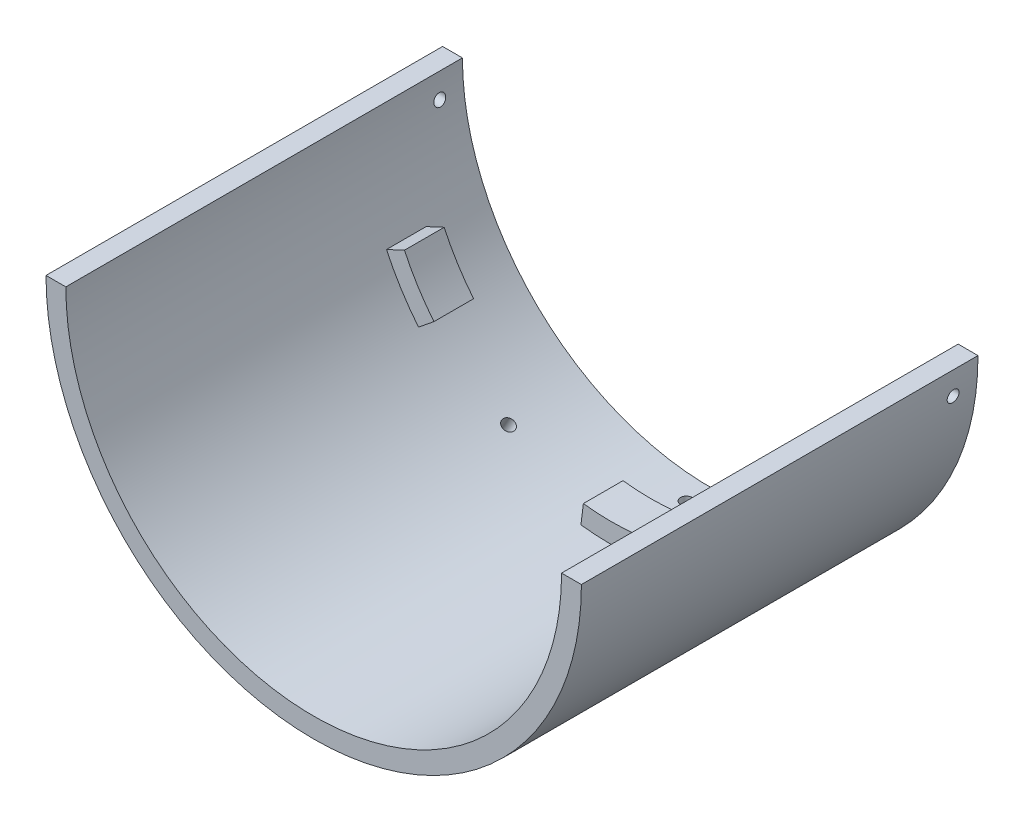
from build123d import *

# Parameters (mm, degrees)
BOSS_EXTRUDE1_DEPTH     = 100
BOSS_EXTRUDE3_DEPTH     = 10
CUT_EXTRUDE1_DEPTH      = 149
CUT_EXTRUDE1_DEPTH_BACK = 16
SKETCH4_R               = 1.5
CUT_EXTRUDE2_DEPTH      = 16
CUT_EXTRUDE2_DEPTH_BACK = 16
SKETCH5_R               = 1.5
CUT_EXTRUDE3_DEPTH      = 16
CUT_EXTRUDE3_DEPTH_BACK = 16
SKETCH6_R               = 1.5
CUT_EXTRUDE4_DEPTH      = 16
CUT_EXTRUDE4_DEPTH_BACK = 16
SKETCH7_R               = 1.5


with BuildPart() as part:
    # Sketch1 → Boss-Extrude1 (new body)
    with BuildSketch(Plane.XY):
        with BuildLine():
            ThreePointArc((62.5, 0), (0, -62.5), (-62.5, 0))
            Line((-62.5, 0), (-67.5, 0))
            ThreePointArc((-67.5, 0), (0, -67.5), (67.5, 0))
            Line((67.5, 0), (62.5, 0))
        make_face()
    extrude(amount=BOSS_EXTRUDE1_DEPTH)

    # Sketch3 → Boss-Extrude3 (add)
    with BuildSketch(Plane.XY.offset(15)):
        with BuildLine():
            Line((-52.112697755, -24.30055005), (-56.64423669, -26.413641359))
            ThreePointArc((-56.64423669, -26.413641359), (-53.00300601, -33.119954015), (-48.571622591, -39.332524441))
            Line((-48.571622591, -39.332524441), (-44.685892784, -36.185922485))
            ThreePointArc((-44.685892784, -36.185922485), (-48.762765529, -30.470357693), (-52.112697755, -24.30055005))
        make_face()
        with BuildLine():
            ThreePointArc((48.571622591, -39.332524441), (53.00300601, -33.119954015), (56.64423669, -26.413641359))
            Line((56.64423669, -26.413641359), (52.112697755, -24.30055005))
            ThreePointArc((52.112697755, -24.30055005), (48.762765529, -30.470357693), (44.685892784, -36.185922485))
            Line((44.685892784, -36.185922485), (48.571622591, -39.332524441))
        make_face()
        with BuildLine():
            Line((-7.007487246, -57.071403719), (-7.616833963, -62.034134478))
            ThreePointArc((-7.616833963, -62.034134478), (0, -62.5), (7.616833963, -62.034134478))
            Line((7.616833963, -62.034134478), (7.007487246, -57.071403719))
            ThreePointArc((7.007487246, -57.071403719), (0, -57.5), (-7.007487246, -57.071403719))
        make_face()
    extrude(amount=BOSS_EXTRUDE3_DEPTH)

    # Sketch4 → Cut-Extrude1 (cut, two sides: drawn at the far end of the back side and taken through both)
    with BuildSketch(Plane.ZY.offset(-62.5).offset(-CUT_EXTRUDE1_DEPTH_BACK)):
        with Locations((6, -6)):
            Circle(SKETCH4_R)
    extrude(amount=CUT_EXTRUDE1_DEPTH + CUT_EXTRUDE1_DEPTH_BACK, mode=Mode.SUBTRACT)

    # Sketch5 → Cut-Extrude2 (cut, two sides: drawn at the far end of the back side and taken through both)
    with BuildSketch(Plane(origin=(0, -62.5, 0), x_dir=(1, 0, 0), z_dir=(0, 1, 0)).offset(-CUT_EXTRUDE2_DEPTH_BACK)):
        with Locations((0, -6)):
            Circle(SKETCH5_R)
    extrude(amount=CUT_EXTRUDE2_DEPTH + CUT_EXTRUDE2_DEPTH_BACK, mode=Mode.SUBTRACT)

    # Sketch6 → Cut-Extrude3 (cut, two sides: drawn at the far end of the back side and taken through both)
    with BuildSketch(Plane(origin=(-30.300601265, -54.663731696, 0), x_dir=(0.8746197071393957, -0.48480962024633734, 0), z_dir=(0.48480962024633734, 0.8746197071393957, 0)).offset(-CUT_EXTRUDE3_DEPTH_BACK)):
        with Locations((-0.663731696, -20)):
            Circle(SKETCH6_R)
    extrude(amount=CUT_EXTRUDE3_DEPTH + CUT_EXTRUDE3_DEPTH_BACK, mode=Mode.SUBTRACT)

    # Sketch7 → Cut-Extrude4 (cut, two sides: drawn at the far end of the back side and taken through both)
    with BuildSketch(Plane(origin=(30.300601265, -54.663731696, 0), x_dir=(0.8746197071393963, 0.4848096202463363, 0), z_dir=(-0.4848096202463362, 0.8746197071393962, 0)).offset(-CUT_EXTRUDE4_DEPTH_BACK)):
        with Locations((0.663731696, -20)):
            Circle(SKETCH7_R)
    extrude(amount=CUT_EXTRUDE4_DEPTH + CUT_EXTRUDE4_DEPTH_BACK, mode=Mode.SUBTRACT)


solid = part.part
